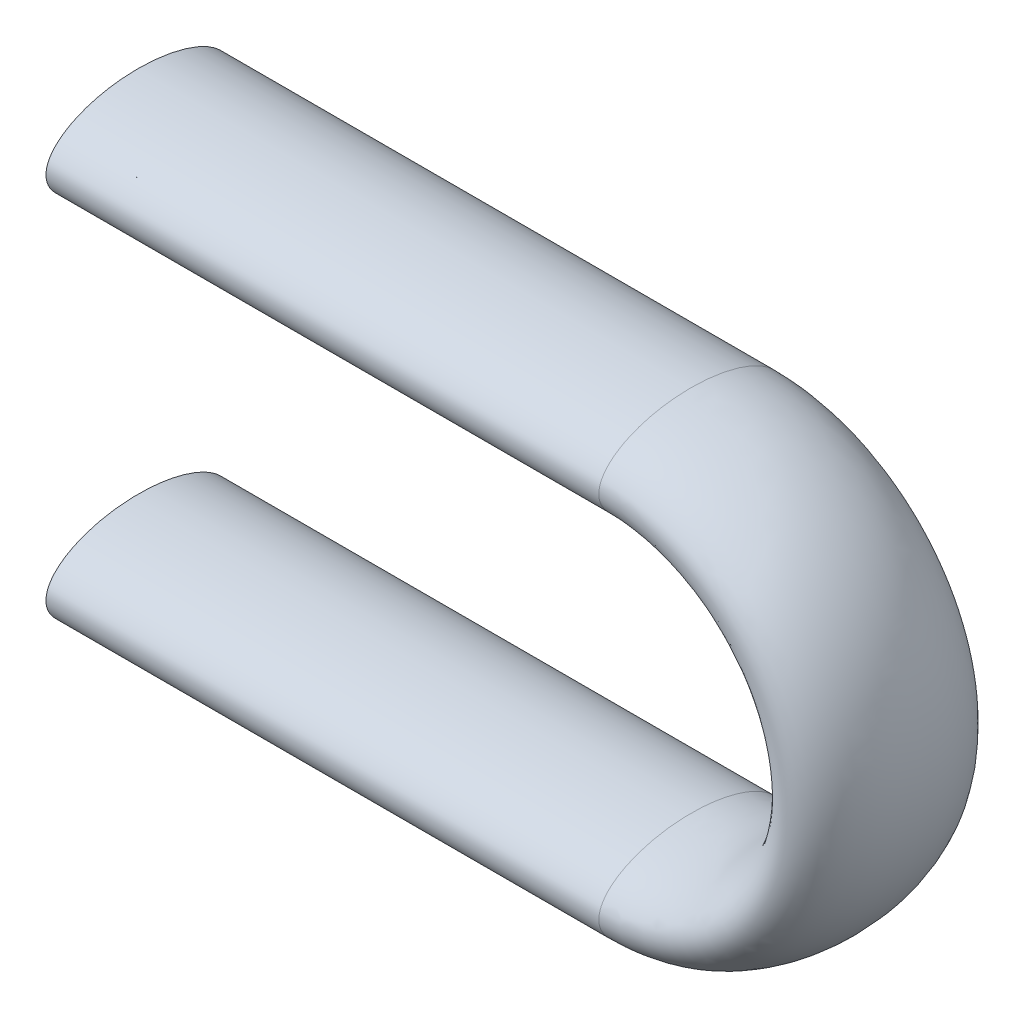
from build123d import *

# Parameters (mm, degrees)
SKETCH2_RX = 50.8
SKETCH2_RY = 25.4
SKETCH3_R  = 19.05


with BuildPart() as part:
    # Sweep1: sweep along a path in Sketch1
    with BuildLine(Plane.XY) as sweep1_path:
        Line((0, 0), (304.8, 0))
        ThreePointArc((304.8, 0), (406.4, 101.6), (304.8, 203.2))
        Line((304.8, 203.2), (0, 203.2))
    # Sketch2 → Sweep1 (sweep)
    with BuildSketch(Plane(origin=(0, 0, 0), x_dir=(0, 0, -1), z_dir=(1, 0, 0))):
        with Locations((0, 0)):
            Ellipse(SKETCH2_RX, SKETCH2_RY)
    sweep(path=sweep1_path.line)

    # Cut-Sweep1: sweep along a path in Sketch1_3
    with BuildLine(Plane.XY) as cut_sweep1_path:
        Line((0, 0), (304.8, 0))
        ThreePointArc((304.8, 0), (406.4, 101.6), (304.8, 203.2))
        Line((304.8, 203.2), (0, 203.2))
    # Sketch3 → Cut-Sweep1 (sweep, cut)
    with BuildSketch(Plane.ZY):
        Circle(SKETCH3_R)
    sweep(path=cut_sweep1_path.line, mode=Mode.SUBTRACT)


solid = part.part
